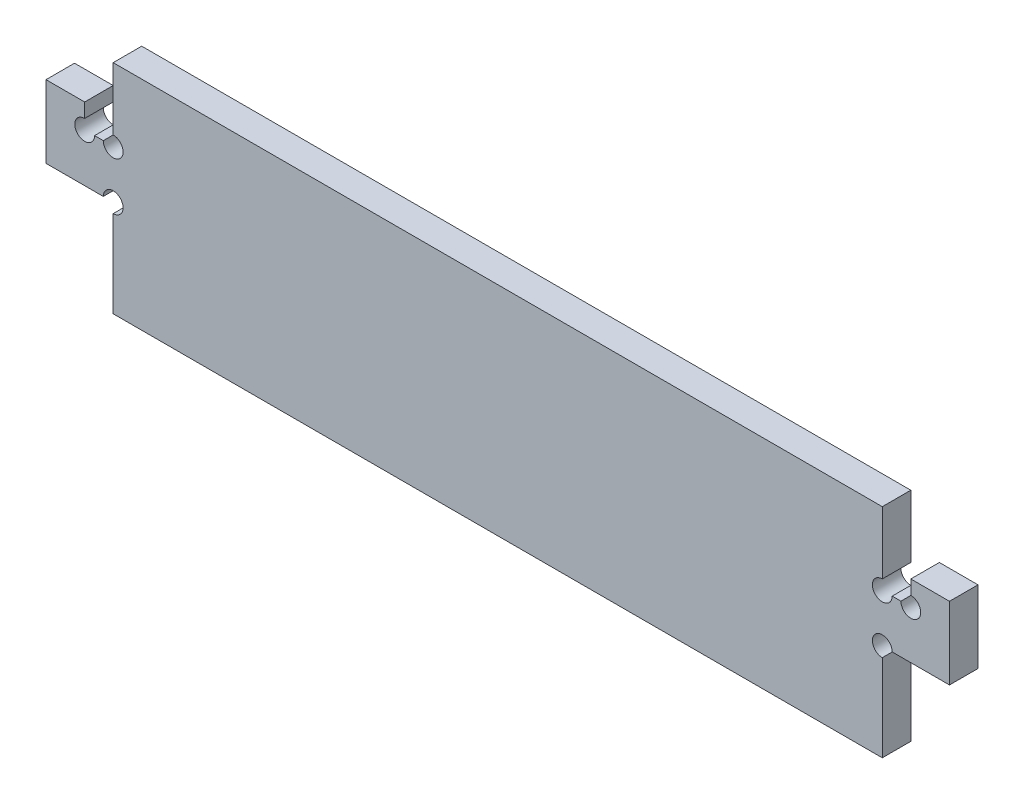
from build123d import *

# Parameters (mm, degrees)
SKETCH1_W           = 159.1
SKETCH1_H           = 45
BOSS_EXTRUDE1_DEPTH = 5.9
BOSS_EXTRUDE3_DEPTH = 5.9
CUT_EXTRUDE1_REACH  = 7.9
SKETCH4_R           = 2.05


with BuildPart() as part:
    # Sketch1 → Boss-Extrude1 (new body)
    with BuildSketch(Plane.XY):
        Rectangle(SKETCH1_W, SKETCH1_H)
    extrude(amount=BOSS_EXTRUDE1_DEPTH)

    # Sketch3 → Boss-Extrude3 (add)
    with BuildSketch(Plane.XY.offset(5.9)):
        Polygon((-79.55, 7.5), (-85.45, 7.5), (-85.45, 12.5), (-93.45, 12.5), (-93.45, -2.5), (-85.45, -2.5), (-79.55, -2.5), align=None)
        Polygon((79.55, -2.5), (79.55, 7.5), (85.45, 7.5), (85.45, 12.5), (93.45, 12.5), (93.45, -2.5), (85.45, -2.5), align=None)
    extrude(amount=-BOSS_EXTRUDE3_DEPTH)

    # Sketch4 → Cut-Extrude1 (cut, up to next)
    with BuildSketch(Plane.XY.offset(5.9), mode=Mode.PRIVATE) as cut_extrude1_sk1:
        with Locations((-79.55, 7.5)):
            Circle(SKETCH4_R)
    cut_extrude1_tool1 = extrude(cut_extrude1_sk1.sketch, amount=-CUT_EXTRUDE1_REACH, mode=Mode.PRIVATE) & part.part
    add(cut_extrude1_tool1.solids().sort_by_distance((-79.55, 7.5, 5.9))[0], mode=Mode.SUBTRACT)
    # Sketch4 → Cut-Extrude1 (cut, up to next)
    with BuildSketch(Plane.XY.offset(5.9), mode=Mode.PRIVATE) as cut_extrude1_sk2:
        with Locations((-79.55, -2.5)):
            Circle(SKETCH4_R)
    cut_extrude1_tool2 = extrude(cut_extrude1_sk2.sketch, amount=-CUT_EXTRUDE1_REACH, mode=Mode.PRIVATE) & part.part
    add(cut_extrude1_tool2.solids().sort_by_distance((-79.55, -2.5, 5.9))[0], mode=Mode.SUBTRACT)
    # Sketch4 → Cut-Extrude1 (cut, up to next)
    with BuildSketch(Plane.XY.offset(5.9), mode=Mode.PRIVATE) as cut_extrude1_sk3:
        with Locations((79.55, -2.5)):
            Circle(SKETCH4_R)
    cut_extrude1_tool3 = extrude(cut_extrude1_sk3.sketch, amount=-CUT_EXTRUDE1_REACH, mode=Mode.PRIVATE) & part.part
    add(cut_extrude1_tool3.solids().sort_by_distance((79.55, -2.5, 5.9))[0], mode=Mode.SUBTRACT)
    # Sketch4 → Cut-Extrude1 (cut, up to next)
    with BuildSketch(Plane.XY.offset(5.9), mode=Mode.PRIVATE) as cut_extrude1_sk4:
        with Locations((79.55, 7.5)):
            Circle(SKETCH4_R)
    cut_extrude1_tool4 = extrude(cut_extrude1_sk4.sketch, amount=-CUT_EXTRUDE1_REACH, mode=Mode.PRIVATE) & part.part
    add(cut_extrude1_tool4.solids().sort_by_distance((79.55, 7.5, 5.9))[0], mode=Mode.SUBTRACT)
    # Sketch4 → Cut-Extrude1 (cut, up to next)
    with BuildSketch(Plane.XY.offset(5.9), mode=Mode.PRIVATE) as cut_extrude1_sk5:
        with Locations((-85.45, 7.5)):
            Circle(SKETCH4_R)
    cut_extrude1_tool5 = extrude(cut_extrude1_sk5.sketch, amount=-CUT_EXTRUDE1_REACH, mode=Mode.PRIVATE) & part.part
    add(cut_extrude1_tool5.solids().sort_by_distance((-85.45, 7.5, 5.9))[0], mode=Mode.SUBTRACT)
    # Sketch4 → Cut-Extrude1 (cut, up to next)
    with BuildSketch(Plane.XY.offset(5.9), mode=Mode.PRIVATE) as cut_extrude1_sk6:
        with Locations((85.45, 7.5)):
            Circle(SKETCH4_R)
    cut_extrude1_tool6 = extrude(cut_extrude1_sk6.sketch, amount=-CUT_EXTRUDE1_REACH, mode=Mode.PRIVATE) & part.part
    add(cut_extrude1_tool6.solids().sort_by_distance((85.45, 7.5, 5.9))[0], mode=Mode.SUBTRACT)


solid = part.part
